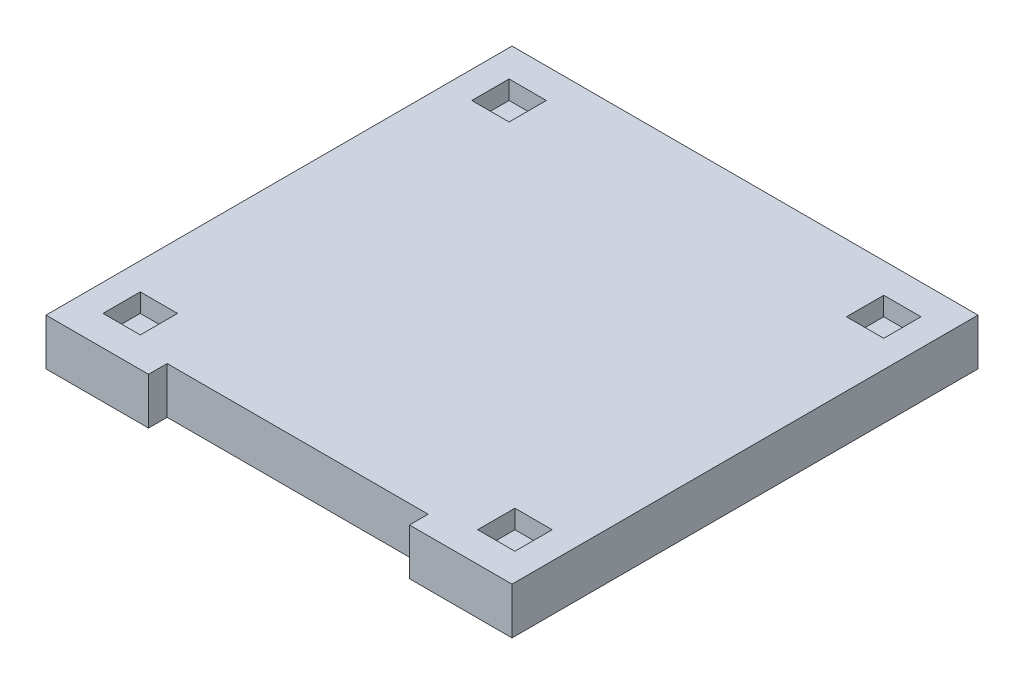
from build123d import *

# Parameters (mm, degrees)
SKETCH_1_W          = 2500
SKETCH_1_H          = 2500
EXTRUDE_2_DEPTH     = 250
SKETCH_5_W          = 200
SKETCH_5_H          = 200
CUT_EXTRUDE_1_DEPTH = 100
SKETCH_6_W          = 200
SKETCH_6_H          = 200
CUT_EXTRUDE_2_DEPTH = 100
SKETCH_7_W          = 200
SKETCH_7_H          = 200
CUT_EXTRUDE_3_DEPTH = 100
CUT_EXTRUDE_4_DEPTH = 250


with BuildPart() as part:
    # 草图1 → 凸台-拉伸2 (new body)
    with BuildSketch(Plane(origin=(-338.184367894, 0, 1455.407434641), x_dir=(1, 0, 0), z_dir=(0, 1, 0))):
        with Locations((338.184367894, 1455.407434641)):
            Rectangle(SKETCH_1_W, SKETCH_1_H)
    extrude(amount=EXTRUDE_2_DEPTH)

    # 草图5 → 切除-拉伸1 (cut)
    with BuildSketch(Plane(origin=(0, 250, 0), x_dir=(1, 0, 0), z_dir=(0, 1, 0))):
        with Locations((1004.982787162, -989.328544112)):
            Rectangle(SKETCH_5_W, SKETCH_5_H)
    extrude(amount=-CUT_EXTRUDE_1_DEPTH, mode=Mode.SUBTRACT)

    # 草图6 → 切除-拉伸2 (cut)
    with BuildSketch(Plane(origin=(0, 250, 0), x_dir=(1, 0, 0), z_dir=(0, 1, 0))):
        with Locations((1004.982787162, 989.328544112)):
            Rectangle(SKETCH_6_W, SKETCH_6_H)
    extrude(amount=-CUT_EXTRUDE_2_DEPTH, mode=Mode.SUBTRACT)

    # 草图7 → 切除-拉伸3 (cut)
    with BuildSketch(Plane(origin=(0, 250, 0), x_dir=(1, 0, 0), z_dir=(0, 1, 0))):
        with Locations((1004.982787162, 989.328544112)):
            Rectangle(SKETCH_7_W, SKETCH_7_H)
        with Locations((1004.982787162, -989.328544112)):
            Rectangle(SKETCH_7_W, SKETCH_7_H)
        with Locations((-1004.982787162, -989.328544112)):
            Rectangle(SKETCH_7_W, SKETCH_7_H)
        with Locations((-1004.982787162, 989.328544112)):
            Rectangle(SKETCH_7_W, SKETCH_7_H)
    extrude(amount=-CUT_EXTRUDE_3_DEPTH, mode=Mode.SUBTRACT)

    # 草图9 → 切除-拉伸4 (cut)
    with BuildSketch(Plane(origin=(0, 250, 0), x_dir=(1, 0, 0), z_dir=(0, 1, 0))):
        Polygon((-700, -1250), (700, -1250), (700, -1150), (0, -1150), (-700, -1150), align=None)
    extrude(amount=-CUT_EXTRUDE_4_DEPTH, mode=Mode.SUBTRACT)


solid = part.part
